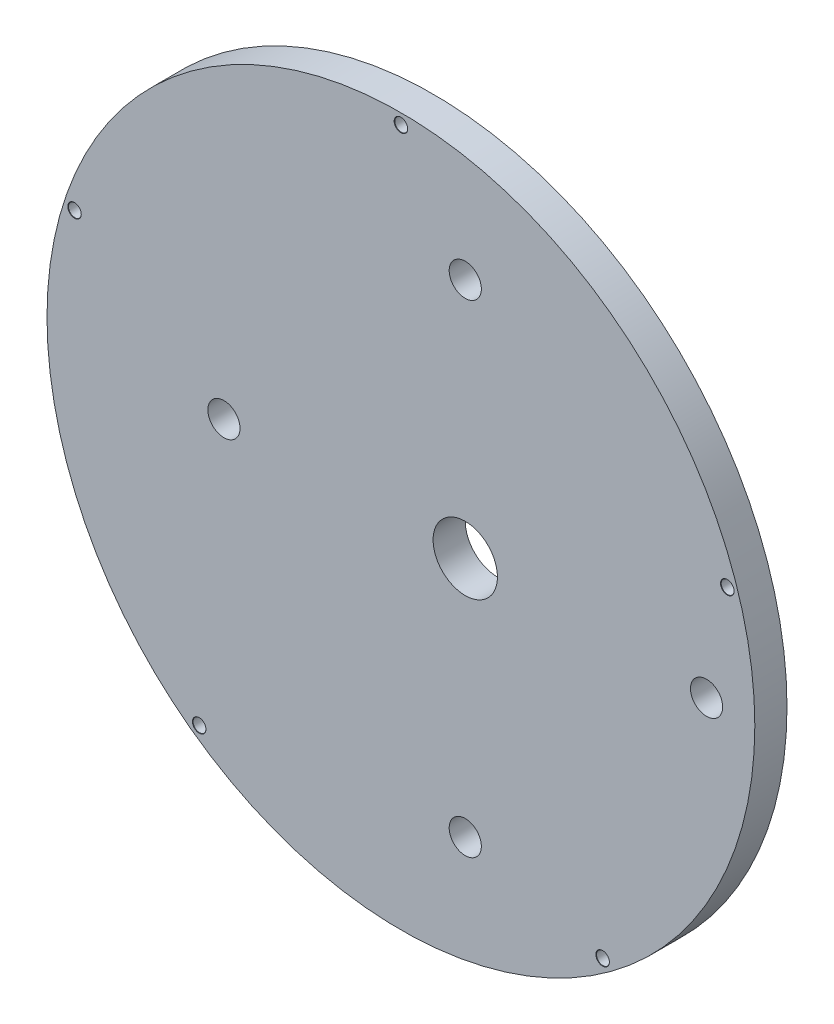
from build123d import *

# Parameters (mm, degrees)
SKETCH1_R                       = 27.5
BOSS_EXTRUDE1_DEPTH             = 1.25
SKETCH3_R                       = 2.5
SKETCH3_R_2                     = 1.25
CUT_EXTRUDE1_DEPTH              = 1
CUT_EXTRUDE1_DEPTH_BACK         = 3.5
F_1_0MM_DOWEL_HOLE1_D           = 1
F_1_0MM_DOWEL_HOLE1_CSINK_D     = 1.05
F_1_0MM_DOWEL_HOLE1_CSINK_ANGLE = 90
CIRPATTERN1_COUNT               = 5


with BuildPart() as part:
    # Sketch1 → Boss-Extrude1 (new body, symmetric)
    with BuildSketch(Plane.XY):
        Circle(SKETCH1_R)
    extrude(amount=BOSS_EXTRUDE1_DEPTH, both=True)

    # Sketch3 → Cut-Extrude1 (cut, two sides)
    with BuildSketch(Plane.XY.offset(1.25)) as cut_extrude1_sk:
        with Locations((5, 0)):
            Circle(SKETCH3_R)
        with Locations((5, 18.75)):
            Circle(SKETCH3_R_2)
        with Locations((-13.75, 0)):
            Circle(SKETCH3_R_2)
        with Locations((23.75, 0)):
            Circle(SKETCH3_R_2)
        with Locations((5, -18.75)):
            Circle(SKETCH3_R_2)
    extrude(amount=CUT_EXTRUDE1_DEPTH, mode=Mode.SUBTRACT)
    extrude(cut_extrude1_sk.sketch, amount=-CUT_EXTRUDE1_DEPTH_BACK, mode=Mode.SUBTRACT)

    # Ø1.0mm Dowel Hole1 (through all)
    with Locations(Plane(origin=(0, 26.666666667, 1.25), x_dir=(1, 0, 0), z_dir=(0, 0, 1))):
        with Locations((0, 0)):
            f_1_0mm_dowel_hole1 = CounterSinkHole(F_1_0MM_DOWEL_HOLE1_D / 2, F_1_0MM_DOWEL_HOLE1_CSINK_D / 2, counter_sink_angle=F_1_0MM_DOWEL_HOLE1_CSINK_ANGLE)

    # CirPattern1: Ø1.0mm Dowel Hole1 ×5 about axis
    cirpattern1_axis = Axis((0, 0, 0), (0, 0, 1))
    for i in range(1, CIRPATTERN1_COUNT):
        add(f_1_0mm_dowel_hole1.rotate(cirpattern1_axis, i * 360 / CIRPATTERN1_COUNT), mode=Mode.SUBTRACT)


solid = part.part
